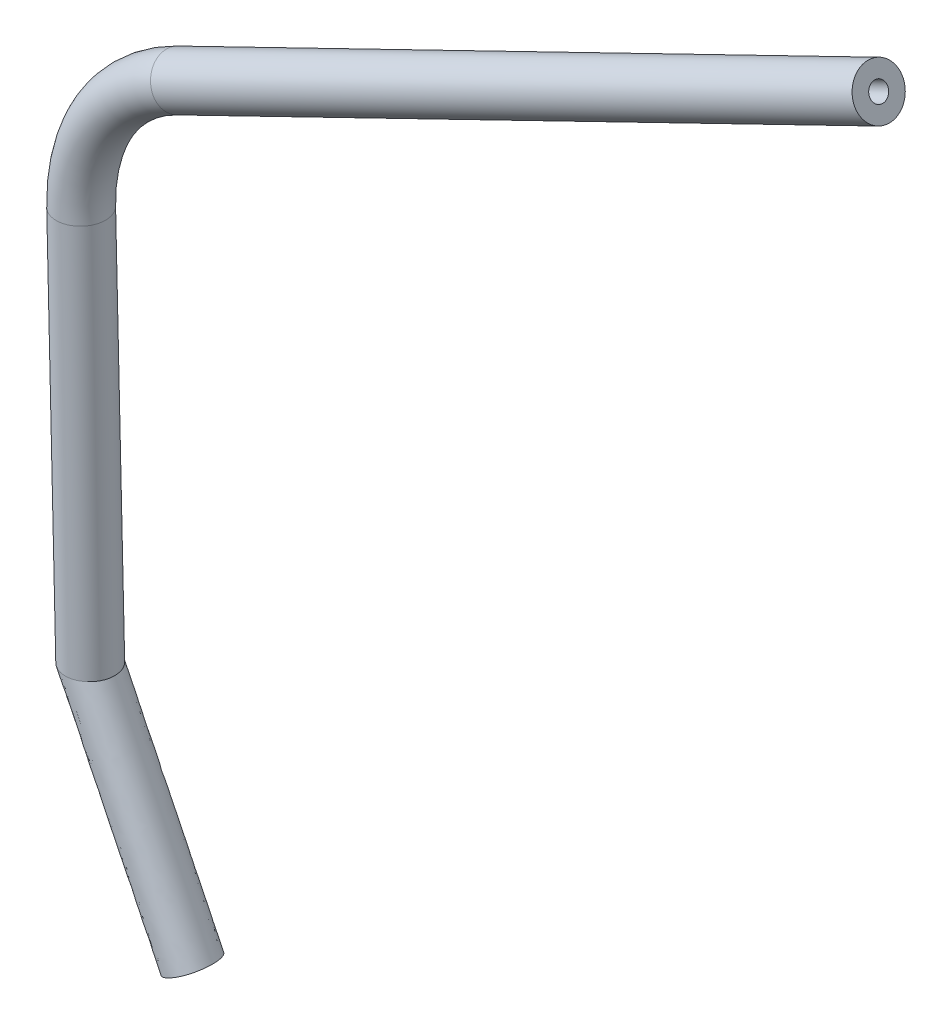
from build123d import *

# Parameters (mm, degrees)
SKETCH5_R               = 12.7
SKETCH5_R_2             = 4.7625
SKETCH6_R               = 12.7
SKETCH6_R_2             = 4.7625
BOSS_EXTRUDE3_DEPTH     = 406.4
SKETCH7_R               = 12.7
SKETCH7_R_2             = 4.7625
BOSS_EXTRUDE4_DEPTH     = 203.2
SKETCH9_R               = 12.7
CUT_EXTRUDE2_DEPTH      = 6.35
SKETCH10_R              = 12.7
SKETCH10_R_2            = 4.7625
CUT_EXTRUDE3_DEPTH      = 462.222817168
CUT_EXTRUDE3_DEPTH_BACK = 462.222817168


with BuildPart() as part:
    # Sweep1: sweep along a path in Sketch4
    with BuildLine(Plane.XY) as sweep1_path:
        ThreePointArc((-38.874671546, 79.949796199), (-75.907697444, 46.273442371), (-88.87582946, -2.072905643))
    # Sketch5 → Sweep1 (sweep)
    with BuildSketch(Plane(origin=(0, 0, 0), x_dir=(1, 0, 0), z_dir=(0, 1, 0))):
        with Locations((-88.87582946, 0)):
            Circle(SKETCH5_R)
        with Locations((-88.87582946, 0)):
            Circle(SKETCH5_R_2, mode=Mode.SUBTRACT)
    sweep(path=sweep1_path.line)

    # Sketch6 → Boss-Extrude3 (add)
    with BuildSketch(Plane(origin=(0, 0, 0), x_dir=(0, 0, -1), z_dir=(0.8993227918843839, 0.43728539421901275, 0))):
        with Locations(Location((0, 88.87582946, 0), (0, 0, 180))):
            Circle(SKETCH6_R)
        with Locations(Location((0, 88.87582946, 0), (0, 0, 180))):
            Circle(SKETCH6_R_2, mode=Mode.SUBTRACT)
    extrude(amount=BOSS_EXTRUDE3_DEPTH)

    # Sketch7 → Boss-Extrude4 (add)
    with BuildSketch(Plane(origin=(0, 0, 0), x_dir=(-0.9997281154099812, -0.023317273828803834, 0), z_dir=(0.023317273828803834, -0.9997281154099812, 0))):
        with Locations((88.87582946, 0)):
            Circle(SKETCH7_R)
        with Locations((88.87582946, 0)):
            Circle(SKETCH7_R_2, mode=Mode.SUBTRACT)
    extrude(amount=BOSS_EXTRUDE4_DEPTH)

    # Sketch9 → Cut-Extrude2 (cut)
    with BuildSketch(Plane(origin=(0, 0, -12.7), x_dir=(-1, 0, 0), z_dir=(0, 0, -1))):
        with Locations((76.269889492, 46.494235168)):
            Circle(SKETCH9_R)
    extrude(amount=-CUT_EXTRUDE2_DEPTH, mode=Mode.SUBTRACT)

    # Sweep2: sweep along a path in Sketch11
    with BuildLine(Plane.XY) as sweep2_path:
        Line((-84.113595449, -205.217095104), (-28.578350384, -319.431089673))
    # Sketch10 → Sweep2 (sweep)
    with BuildSketch(Plane(origin=(4.738070042, -203.144753051, 0), x_dir=(-0.9997281154099812, -0.023317273828803834, 0), z_dir=(0.023317273828803834, -0.9997281154099812, 0))):
        with Locations((88.87582946, 0)):
            Circle(SKETCH10_R)
        with Locations((88.87582946, 0)):
            Circle(SKETCH10_R_2, mode=Mode.SUBTRACT)
    sweep(path=sweep2_path.line)

    # Sketch12 → Cut-Extrude3 (cut, two sides)
    with BuildSketch(Plane.XY) as cut_extrude3_sk:
        Polygon((-41.274897449, -319.727219051), (-20.504520989, -309.627861689), (-15.881803318, -319.134960295), align=None)
    extrude(amount=CUT_EXTRUDE3_DEPTH, mode=Mode.SUBTRACT)
    extrude(cut_extrude3_sk.sketch, amount=-CUT_EXTRUDE3_DEPTH_BACK, mode=Mode.SUBTRACT)


solid = part.part
